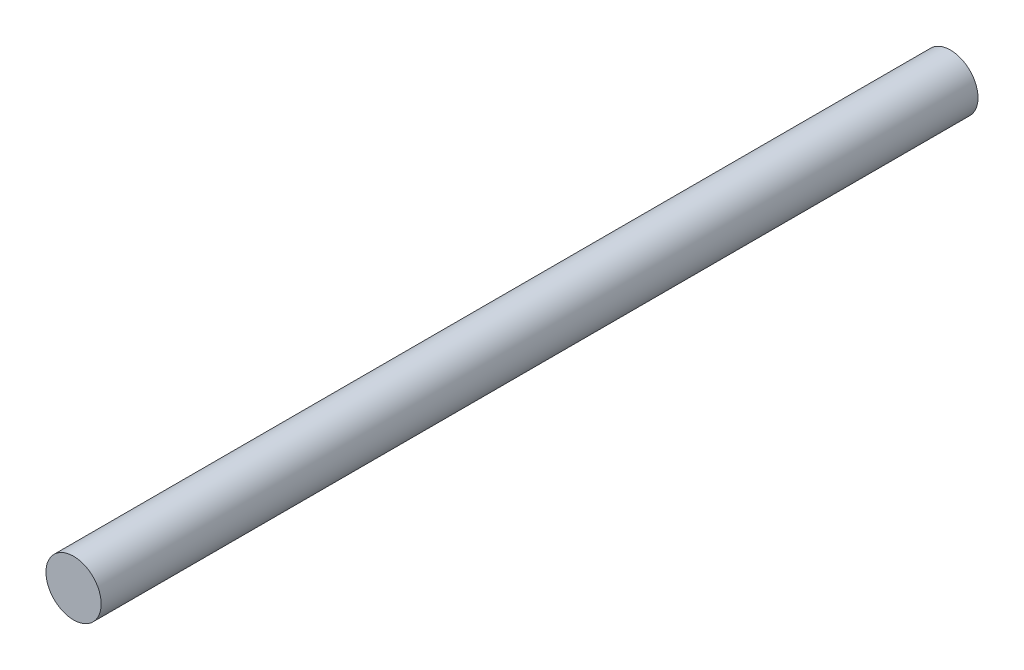
from build123d import *

# Parameters (mm, degrees)
SKETCH1_R           = 2
BOSS_EXTRUDE1_DEPTH = 63.5


with BuildPart() as part:
    # Sketch1 → Boss-Extrude1 (new body)
    with BuildSketch(Plane.XY):
        Circle(SKETCH1_R)
    extrude(amount=BOSS_EXTRUDE1_DEPTH)


solid = part.part
